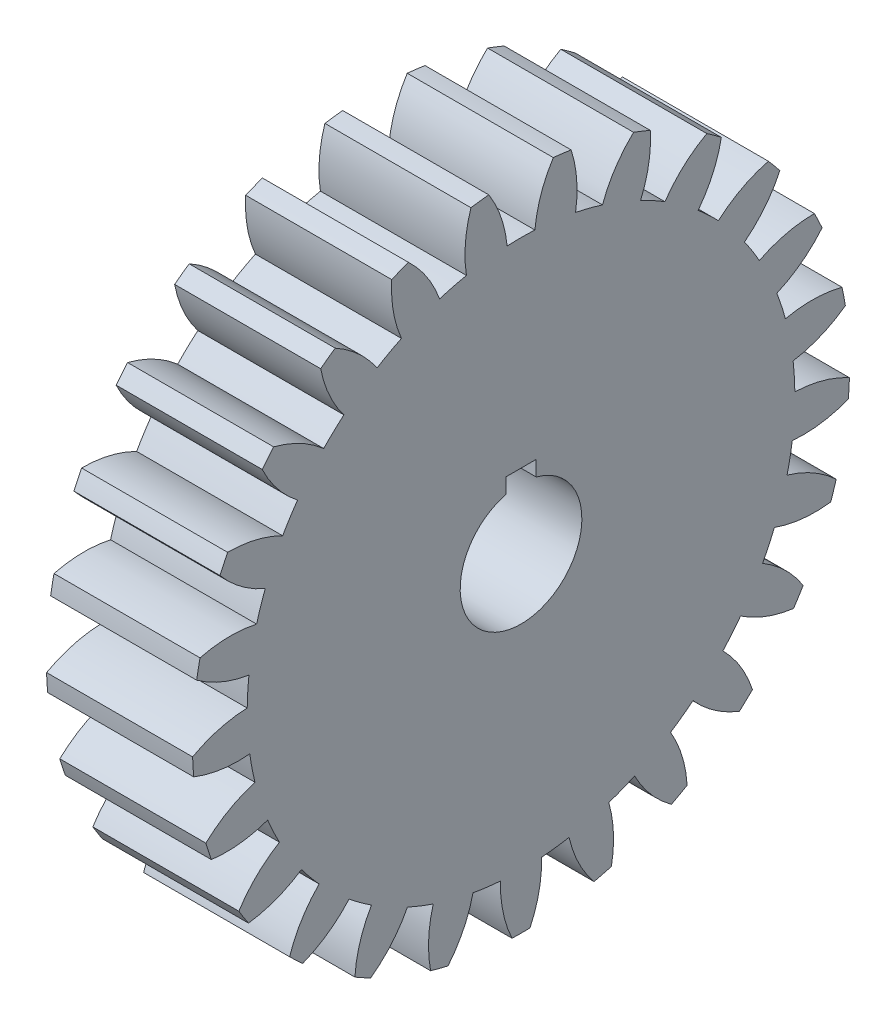
from build123d import *

# Parameters (mm, degrees)
BASPROSKE_W     = 304.8
BASPROSKE_H     = 685.8
TOOTHCUT_DEPTH  = 1017.634801686
TEETHCUTS_COUNT = 25
TEETHCUTS_ANGLE = 345.6
BORSKE_R        = 127
BORE_DEPTH      = 304.8000508
KEYSKE_W        = 63.5
KEYSKE_H        = 154.8384
KEYWAY_DEPTH    = 304.8000508


with BuildPart() as part:
    # BasProSke → Base-Revolve (revolve)
    with BuildSketch(Plane(origin=(0, 0, 0), x_dir=(1, 0, 0), z_dir=(0, 1, 0)), mode=Mode.PRIVATE) as base_revolve_sk:
        with Locations((152.4, 342.9)):
            Rectangle(BASPROSKE_W, BASPROSKE_H)
    revolve(base_revolve_sk.sketch.rotate(Axis((-10, 0, 0), (1, 0, 0)), 180), axis=Axis((-10, 0, 0), (1, 0, 0)))

    # TooCutSke → ToothCut (cut, through all)
    with BuildSketch(Plane(origin=(0, 0, 0), x_dir=(0, 0, -1), z_dir=(1, 0, 0))):
        with BuildLine():
            ThreePointArc((28.961853932, 570.764407973), (0, 571.49873), (-28.961853932, 570.764407973))
            ThreePointArc((-28.961853932, 570.764407973), (-41.564862504, 628.900535379), (-67.343982953, 682.511001556))
            ThreePointArc((-67.343982953, 682.511001556), (0, 685.8254), (67.343982953, 682.511001556))
            ThreePointArc((67.343982953, 682.511001556), (41.564862504, 628.900535379), (28.961853932, 570.764407973))
        make_face()
    toothcut = extrude(amount=TOOTHCUT_DEPTH, mode=Mode.SUBTRACT)

    # TeethCuts: ToothCut ×25 about axis
    teethcuts_axis = Axis((-10, 0, 0), (1, 0, 0))
    for i in range(1, TEETHCUTS_COUNT):
        add(toothcut.rotate(teethcuts_axis, i * TEETHCUTS_ANGLE / (TEETHCUTS_COUNT - 1)), mode=Mode.SUBTRACT)

    # BorSke → Bore (cut, symmetric)
    with BuildSketch(Plane(origin=(0, 0, 0), x_dir=(0, 0, -1), z_dir=(1, 0, 0))):
        with Locations(Location((0, 0, 0), (0, 0, 180))):
            Circle(BORSKE_R)
    extrude(amount=BORE_DEPTH, both=True, mode=Mode.SUBTRACT)

    # KeySke → Keyway (cut, symmetric)
    with BuildSketch(Plane(origin=(0, 0, 0), x_dir=(0, 0, -1), z_dir=(1, 0, 0))):
        with Locations((0, 77.4192)):
            Rectangle(KEYSKE_W, KEYSKE_H)
    extrude(amount=KEYWAY_DEPTH, both=True, mode=Mode.SUBTRACT)


solid = part.part
